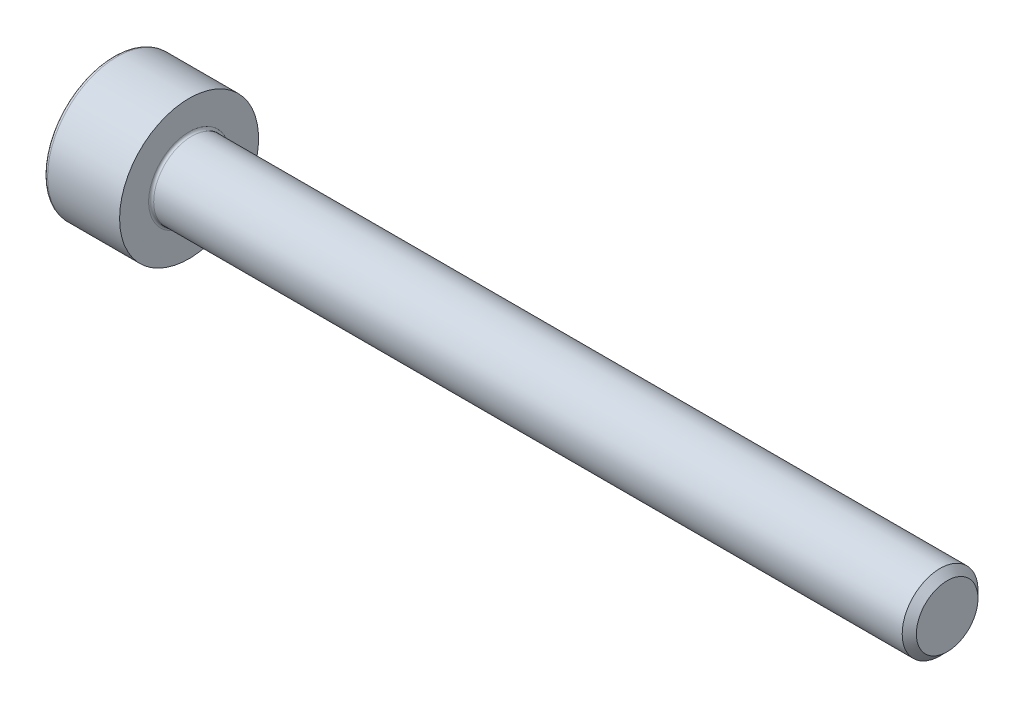
from build123d import *

# Parameters (mm, degrees)
FILLET1_R   = 0.1
FILLET2_R   = 0.15
HEX_2_DEPTH = 1.3


with BuildPart() as part:
    # BodySke → Base-Revolve (revolve)
    with BuildSketch(Plane.XY):
        Polygon((0, 0), (0, 2.75), (3, 2.75), (3, 1.5), (32.7195, 1.5), (33, 1.2195), (33, 0), align=None)
    revolve(axis=Axis((-31.75, 0, 0), (1, 0, 0)))

    # Fillet1
    fillet1_edges = [part.edges().sort_by_distance(p)[0] for p in [
        (3, -1.5, 0),
    ]]
    fillet(fillet1_edges, radius=FILLET1_R)

    # Fillet2
    fillet2_edges = [part.edges().sort_by_distance(p)[0] for p in [
        (0, -2.75, 0),
    ]]
    fillet(fillet2_edges, radius=FILLET2_R)

    # Sketch2 → Hex-PreBroach (revolve, cut)
    with BuildSketch(Plane.XY):
        Polygon((0, 1.28), (1.3, 1.28), (2.039008345, 0), (0, 0), align=None)
    revolve(axis=Axis((0, 0, 0), (1, 0, 0)), mode=Mode.SUBTRACT)

    # Sketch3 → Hex 2 (cut)
    with BuildSketch(Plane(origin=(0, 0, 0), x_dir=(0, 0.5, 0.866025404), z_dir=(-1, 0, 0))):
        Polygon((0.739008345, 1.28), (-0.739008345, 1.28), (-1.478016689, 0), (-0.739008345, -1.28), (0.739008345, -1.28), (1.478016689, 0), align=None)
    extrude(amount=-HEX_2_DEPTH, mode=Mode.SUBTRACT)


solid = part.part
